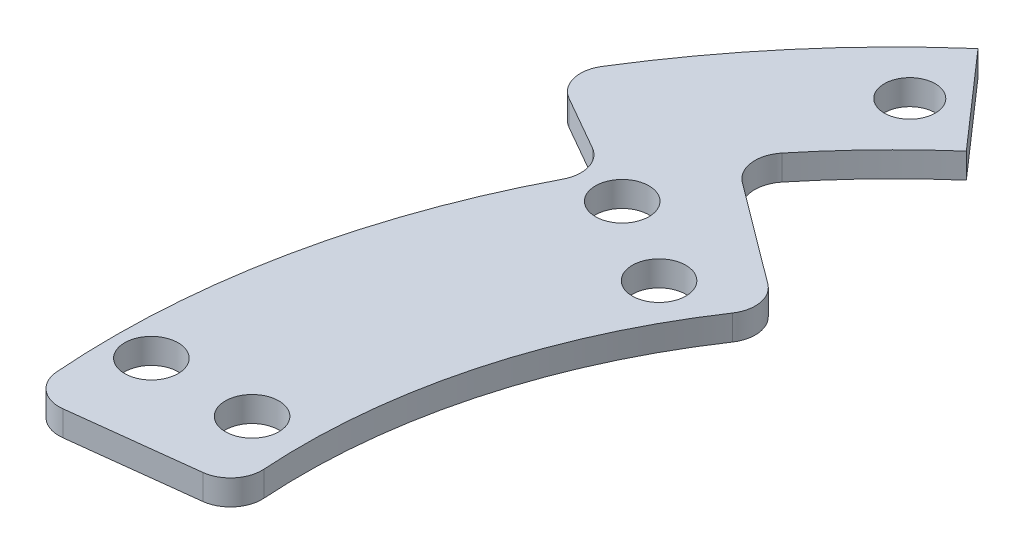
from build123d import *

# Parameters (mm, degrees)
SKETCH1_R               = 2.125
BOSS_EXTRUDE1_DEPTH     = 2
BOSS_EXTRUDE3_DEPTH     = 2
BOSS_EXTRUDE4_DEPTH     = 2
FILLET1_R               = 2.5
SKETCH6_R               = 2.025
CUT_EXTRUDE1_DEPTH      = 1
CUT_EXTRUDE1_DEPTH_BACK = 3


with BuildPart() as part:
    # Sketch1 → Boss-Extrude1 (new body)
    with BuildSketch(Plane(origin=(0, 0, 0), x_dir=(1, 0, 0), z_dir=(0, 1, 0))):
        with BuildLine():
            Line((-37.655823606, 28.125414637), (-49.673639651, 37.101610798))
            ThreePointArc((-49.673639651, 37.101610798), (-59.88740123, 16.046780796), (-61.569439235, -7.294117647))
            Line((-61.569439235, -7.294117647), (-46.673607162, -5.529411765))
            ThreePointArc((-46.673607162, -5.529411765), (-45.398513836, 12.16449512), (-37.655823606, 28.125414637))
        make_face()
        with Locations((-44.167295593, 25.5)):
            Circle(SKETCH1_R, mode=Mode.SUBTRACT)
        with Locations((-51.095498823, 29.5)):
            Circle(SKETCH1_R, mode=Mode.SUBTRACT)
        with Locations((-59, 0)):
            Circle(SKETCH1_R, mode=Mode.SUBTRACT)
        with Locations((-51, 0)):
            Circle(SKETCH1_R, mode=Mode.SUBTRACT)
    extrude(amount=BOSS_EXTRUDE1_DEPTH)

    # Sketch3 → Boss-Extrude3 (add)
    with BuildSketch(Plane(origin=(0, 0, 0), x_dir=(1, 0, 0), z_dir=(0, 1, 0))):
        with BuildLine():
            Line((-62.506368953, 35.734490906), (-53.824928821, 30.771367169))
            ThreePointArc((-53.824928821, 30.771367169), (-51.845987454, 33.999905661), (-49.673639651, 37.101610798))
            Line((-49.673639651, 37.101610798), (-57.685517014, 43.085741572))
            ThreePointArc((-57.685517014, 43.085741572), (-60.208243494, 39.483761413), (-62.506368953, 35.734490906))
        make_face()
    extrude(amount=BOSS_EXTRUDE3_DEPTH)

    # Sketch5 → Boss-Extrude4 (add)
    with BuildSketch(Plane(origin=(0, 0, 0), x_dir=(1, 0, 0), z_dir=(0, 1, 0))):
        with BuildLine():
            Line((-47.466920684, 54.137708123), (-40.874292811, 46.618581995))
            ThreePointArc((-40.874292811, 46.618581995), (-45.523347894, 42.09067351), (-49.673639651, 37.101610798))
            Line((-49.673639651, 37.101610798), (-57.685517014, 43.085741572))
            ThreePointArc((-57.685517014, 43.085741572), (-52.865823361, 48.879491818), (-47.466920684, 54.137708123))
        make_face()
    extrude(amount=BOSS_EXTRUDE4_DEPTH)

    # Fillet1
    fillet1_edges = [part.edges().sort_by_distance(p)[0] for p in [
        (-53.824928821, 1, -30.771367169),
        (-62.506368953, 1, -35.734490906),
        (-49.673639651, 1, -37.101610798),
        (-46.673607162, 1, 5.529411765),
        (-61.569439235, 1, 7.294117647),
        (-37.655823606, 1, -28.125414637),
    ]]
    fillet(fillet1_edges, radius=FILLET1_R)

    # Sketch6 → Cut-Extrude1 (cut, two sides)
    with BuildSketch(Plane(origin=(0, 2, 0), x_dir=(1, 0, 0), z_dir=(0, 1, 0))) as cut_extrude1_sk:
        with Locations((-46.746660862, 47.99739262)):
            Circle(SKETCH6_R)
    extrude(amount=CUT_EXTRUDE1_DEPTH, mode=Mode.SUBTRACT)
    extrude(cut_extrude1_sk.sketch, amount=-CUT_EXTRUDE1_DEPTH_BACK, mode=Mode.SUBTRACT)


solid = part.part
